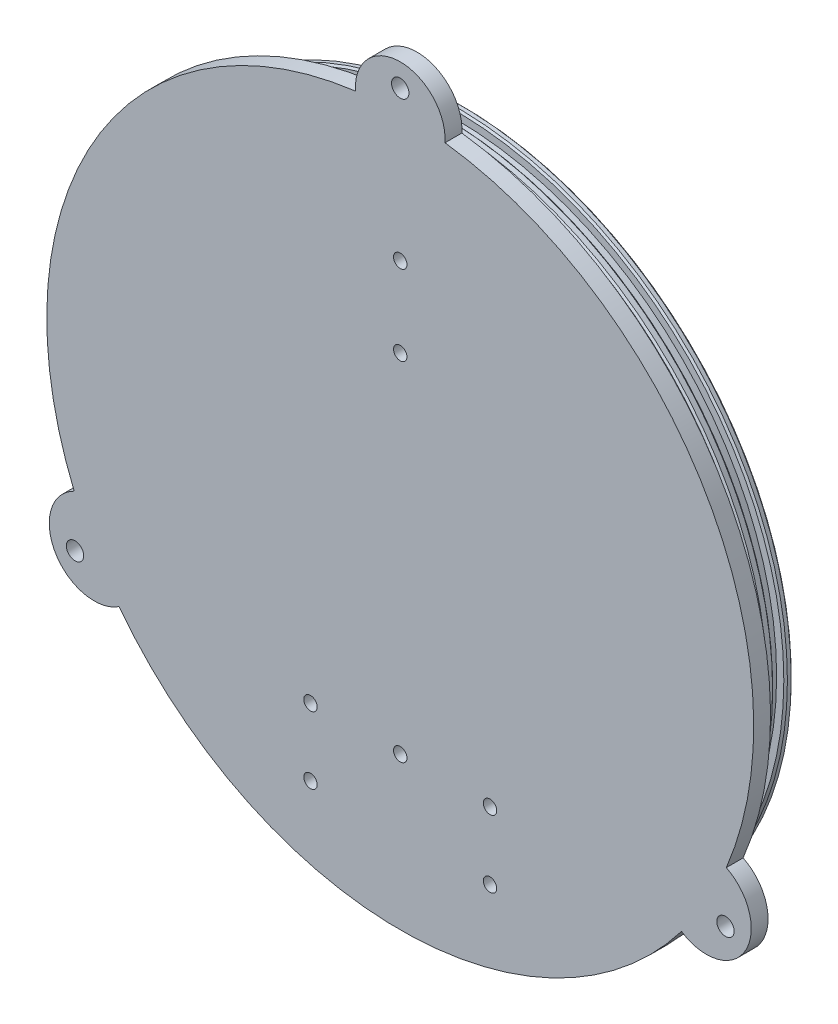
from build123d import *

# Parameters (mm, degrees)
SKETCH1_R                        = 100.0125
EXTRUDE1_DEPTH                   = 4.7625
SKETCH2_R                        = 93.6625
EXTRUDE2_DEPTH                   = 12.7
SKETCH3_R                        = 87.3125
CUT_EXTRUDE1_DEPTH               = 12.7
SKETCH4_W                        = 3.175
SKETCH4_H                        = 2.54
EXTRUDE3_DEPTH                   = 4.7625
F_10_0_1935_DIAMETER_HOLE1_D     = 4.9149
F_10_0_1935_DIAMETER_HOLE1_DEPTH = 330.2
F_10_0_1935_DIAMETER_HOLE1_TIP   = 1.476584928
CHAMFER1_SIZE                    = 0.508
F_6_CLEARANCE_HOLE1_D            = 3.7973
F_6_CLEARANCE_HOLE1_DEPTH        = 6.35
F_6_CLEARANCE_HOLE1_TIP          = 1.140824014
F_6_CLEARANCE_HOLE2_D            = 3.7973
F_6_CLEARANCE_HOLE2_DEPTH        = 25.4
F_6_CLEARANCE_HOLE2_TIP          = 1.140824014


with BuildPart() as part:
    # Sketch1 → Extrude1 (new body)
    with BuildSketch(Plane.XY):
        Circle(SKETCH1_R)
    extrude(amount=EXTRUDE1_DEPTH)

    # Sketch2 → Extrude2 (add)
    with BuildSketch(Plane(origin=(0, 0, 0), x_dir=(-1, 0, 0), z_dir=(0, 0, -1))):
        Circle(SKETCH2_R)
    extrude(amount=EXTRUDE2_DEPTH)

    # Sketch3 → Cut-Extrude1 (cut)
    with BuildSketch(Plane(origin=(0, 0, -12.7), x_dir=(-1, 0, 0), z_dir=(0, 0, -1))):
        Circle(SKETCH3_R)
    extrude(amount=-CUT_EXTRUDE1_DEPTH, mode=Mode.SUBTRACT)

    # Sketch4 → Cut-Revolve1 (revolve, cut)
    with BuildSketch(Plane(origin=(0, 0, 0), x_dir=(0, 0, -1), z_dir=(1, 0, 0))):
        with Locations((3.395858926, 92.3925)):
            Rectangle(SKETCH4_W, SKETCH4_H)
        with Locations((9.028423409, 92.3925)):
            Rectangle(SKETCH4_W, SKETCH4_H)
    revolve(axis=Axis((0, 0, 0), (0, 0, -1)), mode=Mode.SUBTRACT)

    # Sketch5 → Extrude3 (add)
    with BuildSketch(Plane.XY.offset(4.7625)):
        with BuildLine():
            ThreePointArc((-12.674375762, 99.206150794), (0, 112.7125), (12.674375762, 99.206150794))
            ThreePointArc((12.674375762, 99.206150794), (0, 100.0125), (-12.674375762, 99.206150794))
        make_face()
        with BuildLine():
            ThreePointArc((92.25223468, -38.62674401), (97.611888324, -56.35625), (79.577858918, -60.579406784))
            ThreePointArc((79.577858918, -60.579406784), (86.613365696, -50.00625), (92.25223468, -38.62674401))
        make_face()
        with BuildLine():
            ThreePointArc((-79.577858918, -60.579406784), (-97.611888324, -56.35625), (-92.25223468, -38.62674401))
            ThreePointArc((-92.25223468, -38.62674401), (-86.613365696, -50.00625), (-79.577858918, -60.579406784))
        make_face()
    extrude(amount=-EXTRUDE3_DEPTH)

    # #10 (0.1935) Diameter Hole1
    with Locations(Plane(origin=(0, 106.25582337, 4.7625), x_dir=(1, 0, 0), z_dir=(0, 0, 1))):
        with Locations((0, 0), (-92.020242338, -159.383735055), (92.020242338, -159.383735055)):
            Hole(F_10_0_1935_DIAMETER_HOLE1_D / 2, depth=F_10_0_1935_DIAMETER_HOLE1_DEPTH)
            with Locations((0, 0, -(F_10_0_1935_DIAMETER_HOLE1_DEPTH + F_10_0_1935_DIAMETER_HOLE1_TIP / 2))):  # 118° drill point
                Cone(0, F_10_0_1935_DIAMETER_HOLE1_D / 2, F_10_0_1935_DIAMETER_HOLE1_TIP, mode=Mode.SUBTRACT)

    # Chamfer1
    chamfer1_edges = [part.edges().sort_by_distance(p)[0] for p in [
        (93.6625, 0, -1.808358926),
        (93.6625, 0, -4.983358926),
        (93.6625, 0, -7.440923409),
        (93.6625, 0, -10.615923409),
        (93.6625, 0, -12.7),
    ]]
    chamfer(chamfer1_edges, length=CHAMFER1_SIZE)

    # #6 Clearance Hole1
    with Locations(Plane(origin=(0, 63.952783211, 4.7625), x_dir=(1, 0, 0), z_dir=(0, 0, 1))):
        with Locations((0, 0), (0, -22.606), (0, -120.904)):
            Hole(F_6_CLEARANCE_HOLE1_D / 2, depth=F_6_CLEARANCE_HOLE1_DEPTH)
            with Locations((0, 0, -(F_6_CLEARANCE_HOLE1_DEPTH + F_6_CLEARANCE_HOLE1_TIP / 2))):  # 118° drill point
                Cone(0, F_6_CLEARANCE_HOLE1_D / 2, F_6_CLEARANCE_HOLE1_TIP, mode=Mode.SUBTRACT)

    # #6 Clearance Hole2
    with Locations(Plane(origin=(25.4, -57.15, 0), x_dir=(-1, 0, 0), z_dir=(0, 0, -1))):
        with Locations((0, 0), (50.8, 0), (0, -19.05), (50.8, -19.05)):
            Hole(F_6_CLEARANCE_HOLE2_D / 2, depth=F_6_CLEARANCE_HOLE2_DEPTH)
            with Locations((0, 0, -(F_6_CLEARANCE_HOLE2_DEPTH + F_6_CLEARANCE_HOLE2_TIP / 2))):  # 118° drill point
                Cone(0, F_6_CLEARANCE_HOLE2_D / 2, F_6_CLEARANCE_HOLE2_TIP, mode=Mode.SUBTRACT)


solid = part.part
